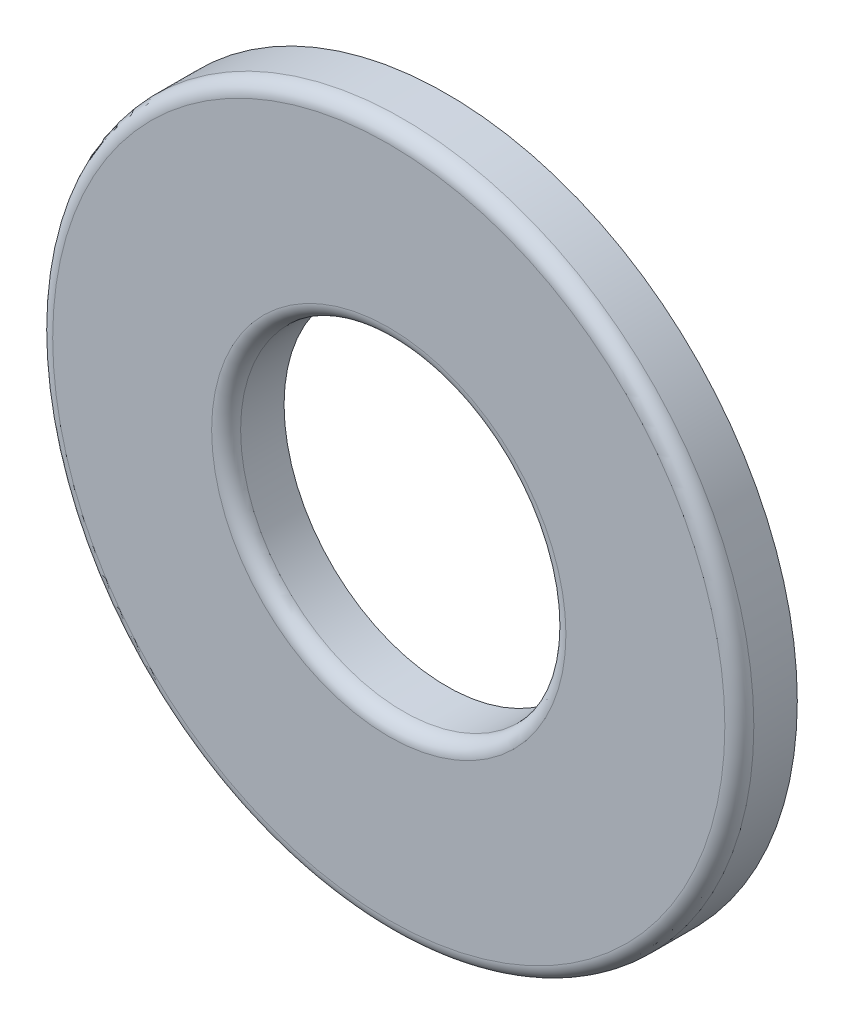
from build123d import *

# Parameters (mm, degrees)
SKETCH3_R                = 4.7625
SKETCH3_R_2              = 2.2098
BOSS_EXTRUDE1_DEPTH      = 0.3937
BOSS_EXTRUDE1_DEPTH_BACK = 0.3937
FILLET1_R                = 0.19685


with BuildPart() as part:
    # Sketch3 → Boss-Extrude1 (new body, two sides)
    with BuildSketch(Plane.XY) as boss_extrude1_sk:
        Circle(SKETCH3_R)
        Circle(SKETCH3_R_2, mode=Mode.SUBTRACT)
    extrude(amount=BOSS_EXTRUDE1_DEPTH)
    extrude(boss_extrude1_sk.sketch, amount=-BOSS_EXTRUDE1_DEPTH_BACK)

    # Fillet1
    fillet1_edges = [part.edges().sort_by_distance(p)[0] for p in [
        (-4.7625, 0, 0.3937),
        (-2.2098, 0, 0.3937),
    ]]
    fillet(fillet1_edges, radius=FILLET1_R)


solid = part.part
